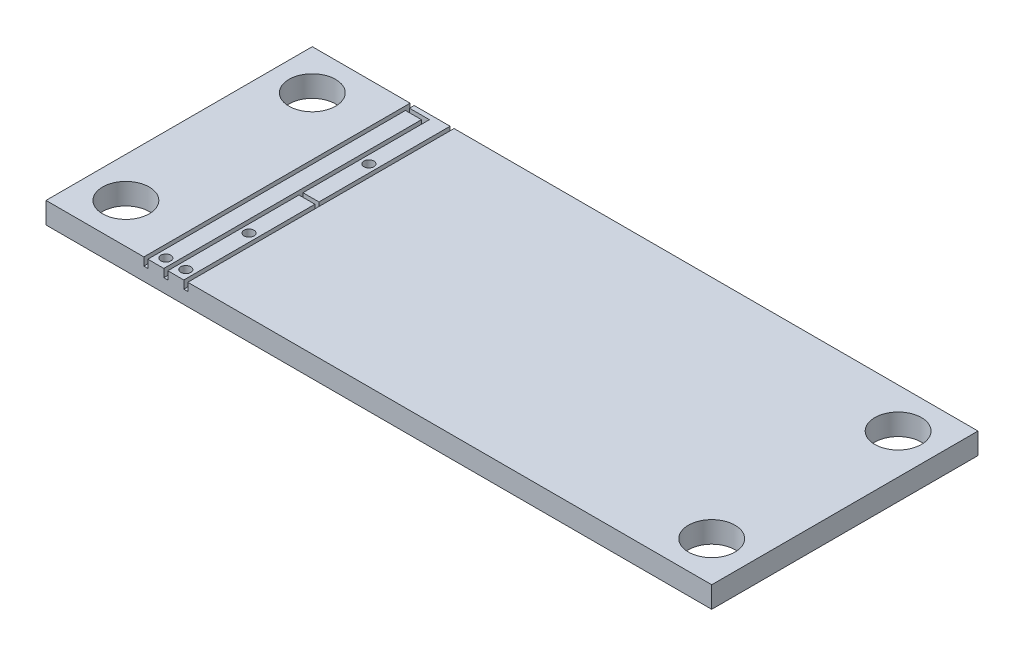
from build123d import *

# Parameters (mm, degrees)
SKETCH1_W           = 50
SKETCH1_H           = 20
SKETCH1_R           = 1.75
BOSS_EXTRUDE1_DEPTH = 1.6
SKETCH3_R           = 0.375
CUT_EXTRUDE1_DEPTH  = 2.6
SKETCH2_W           = 0.3
SKETCH2_H           = 20
SKETCH2_W_2         = 1.5
SKETCH2_H_2         = 0.3
CUT_EXTRUDE2_DEPTH  = 0.6


with BuildPart() as part:
    # Sketch1 → Boss-Extrude1 (new body)
    with BuildSketch(Plane(origin=(0, 0, 0), x_dir=(1, 0, 0), z_dir=(0, 1, 0))):
        with Locations((25, 10)):
            Rectangle(SKETCH1_W, SKETCH1_H)
        with Locations((3, 17)):
            Circle(SKETCH1_R, mode=Mode.SUBTRACT)
        with Locations((47, 3)):
            Circle(SKETCH1_R, mode=Mode.SUBTRACT)
        with Locations((3, 3)):
            Circle(SKETCH1_R, mode=Mode.SUBTRACT)
        with Locations((47, 17)):
            Circle(SKETCH1_R, mode=Mode.SUBTRACT)
    extrude(amount=BOSS_EXTRUDE1_DEPTH)

    # Sketch3 → Cut-Extrude1 (cut, through all)
    with BuildSketch(Plane(origin=(0, 1.6, 0), x_dir=(1, 0, 0), z_dir=(0, 1, 0))):
        with Locations((8.25, 0.75)):
            Circle(SKETCH3_R)
        with Locations((9.75, 0.75)):
            Circle(SKETCH3_R)
        with Locations((9.75, 5.5)):
            Circle(SKETCH3_R)
        with Locations((9.75, 14.5)):
            Circle(SKETCH3_R)
    extrude(amount=-CUT_EXTRUDE1_DEPTH, mode=Mode.SUBTRACT)

    # Sketch2 → Cut-Extrude2 (cut)
    with BuildSketch(Plane(origin=(0, 1.6, 0), x_dir=(1, 0, 0), z_dir=(0, 1, 0))):
        Polygon((9.15, 0), (9.15, 19.65), (7.5, 19.65), (7.5, 19.35), (8.85, 19.35), (8.85, 0), align=None)
        with Locations((7.5, 10)):
            Rectangle(SKETCH2_W, SKETCH2_H)
        with Locations((10.5, 10)):
            Rectangle(SKETCH2_W, SKETCH2_H)
        with Locations((9.75, 10)):
            Rectangle(SKETCH2_W_2, SKETCH2_H_2)
    extrude(amount=-CUT_EXTRUDE2_DEPTH, mode=Mode.SUBTRACT)


solid = part.part
